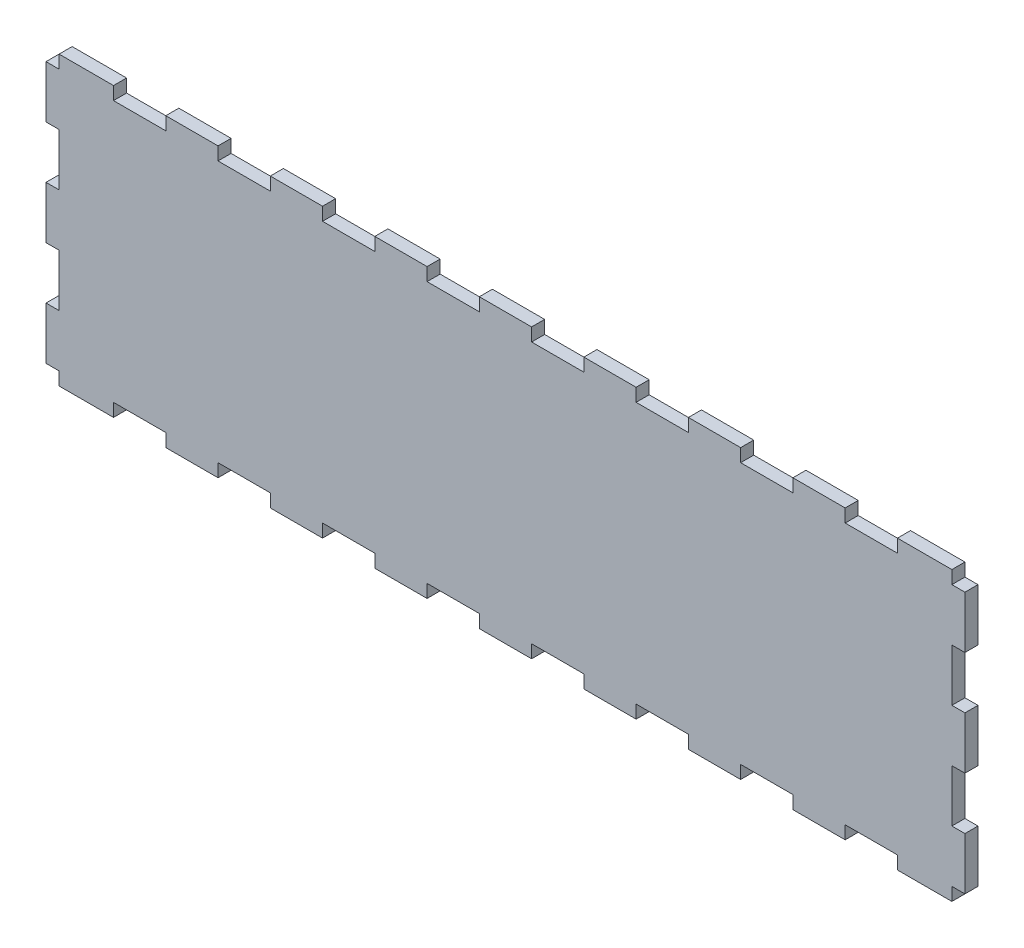
from build123d import *

# Parameters (mm, degrees)
BOSS_EXTRUDE1_DEPTH = 3
SKETCH3_W           = 3
SKETCH3_H           = 12
BOSS_EXTRUDE2_DEPTH = 3


with BuildPart() as part:
    # Sketch2 → Boss-Extrude1 (new body)
    with BuildSketch(Plane(origin=(-276.446036152, 132.735684364, 0), x_dir=(1, 0, 0), z_dir=(0, 0, 1))):
        Polygon((-78, 3), (-78, 0), (-90, 0), (-90, 3), (-102.5, 3), (-102.5, -62.99938194), (-90, -62.99938194), (-90, -59.99938194), (-78, -59.99938194), (-78, -62.99938194), (-66, -62.99938194), (-66, -59.99938194), (-54, -59.99938194), (-54, -62.99938194), (-42, -62.99938194), (-42, -59.99938194), (-30, -59.99938194), (-30, -62.99938194), (-18, -62.99938194), (-18, -59.99938194), (-6, -59.99938194), (-6, -62.99938194), (6, -62.99938194), (6, -59.99938194), (18, -59.99938194), (18, -62.99938194), (30, -62.99938194), (30, -59.99938194), (42, -59.99938194), (42, -62.99938194), (54, -62.99938194), (54, -59.99938194), (66, -59.99938194), (66, -62.99938194), (78, -62.99938194), (78, -59.99938194), (90, -59.99938194), (90, -62.99938194), (102.5, -62.99938194), (102.5, 3), (90, 3), (90, 0), (78, 0), (78, 3), (66, 3), (66, 0), (54, 0), (54, 3), (42, 3), (42, 0), (30, 0), (30, 3), (18, 3), (18, 0), (6, 0), (6, 3), (-6, 3), (-6, 0), (-18, 0), (-18, 3), (-30, 3), (-30, 0), (-42, 0), (-42, 3), (-54, 3), (-54, 0), (-66, 0), (-66, 3), align=None)
    extrude(amount=BOSS_EXTRUDE1_DEPTH)

    # Sketch3 → Boss-Extrude2 (add)
    with BuildSketch(Plane(origin=(-276.446036152, 132.735684364, 3), x_dir=(1, 0, 0), z_dir=(0, 0, 1))):
        with Locations((-104, -6)):
            Rectangle(SKETCH3_W, SKETCH3_H)
        with Locations((104, -6)):
            Rectangle(SKETCH3_W, SKETCH3_H)
        with Locations((104, -30)):
            Rectangle(SKETCH3_W, SKETCH3_H)
        with Locations((104, -54)):
            Rectangle(SKETCH3_W, SKETCH3_H)
        with Locations((-104, -30)):
            Rectangle(SKETCH3_W, SKETCH3_H)
        with Locations((-104, -54)):
            Rectangle(SKETCH3_W, SKETCH3_H)
    extrude(amount=-BOSS_EXTRUDE2_DEPTH)


solid = part.part
